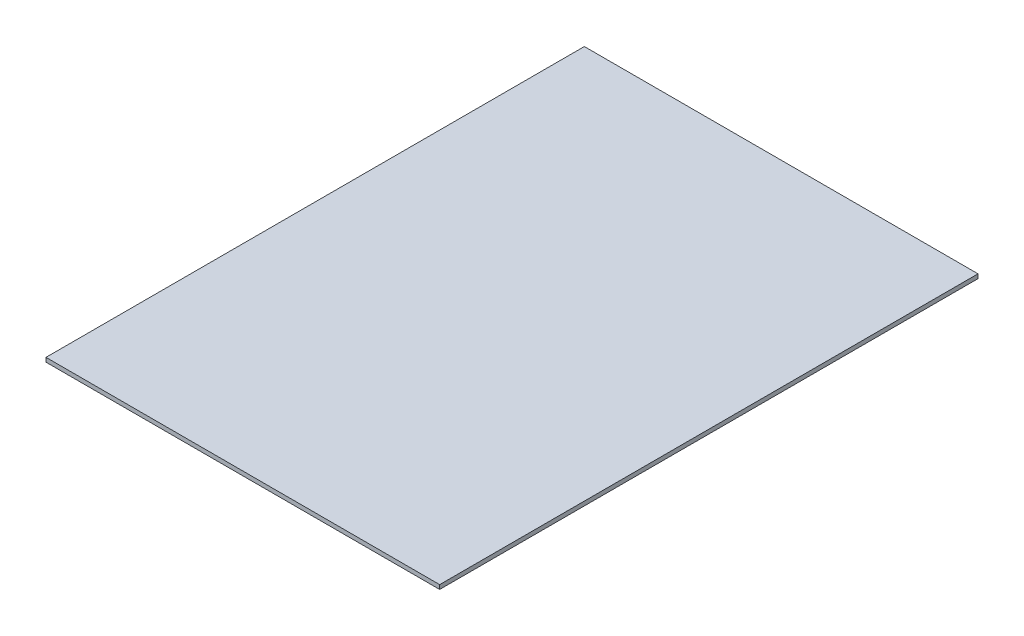
from build123d import *

# Parameters (mm, degrees)
SKETCH_1_W      = 234
SKETCH_1_H      = 320
EXTRUDE_1_DEPTH = 2.5


with BuildPart() as part:
    # Эскиз1 → Бобышка-Вытянуть1 (new body)
    with BuildSketch(Plane(origin=(0, 0, 0), x_dir=(1, 0, 0), z_dir=(0, 1, 0))):
        Rectangle(SKETCH_1_W, SKETCH_1_H)
    extrude(amount=EXTRUDE_1_DEPTH)


solid = part.part
